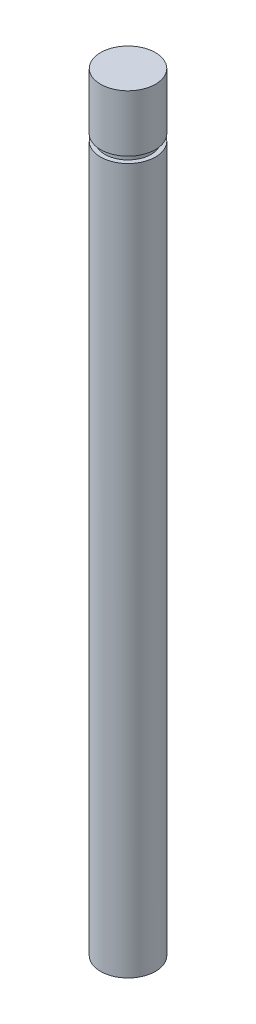
from build123d import *

# Parameters (mm, degrees)
SKETCH1_R           = 3.175
BOSS_EXTRUDE1_DEPTH = 88.9
CUT_EXTRUDE1_DEPTH  = 50.8
CUT_EXTRUDE2_START  = -6.5532
SKETCH3_R           = 3.175
SKETCH3_R_2         = 2.667
CUT_EXTRUDE2_DEPTH  = 0.7366


with BuildPart() as part:
    # Sketch1 → Boss-Extrude1 (new body)
    with BuildSketch(Plane(origin=(0, 0, 0), x_dir=(1, 0, 0), z_dir=(0, 1, 0))):
        Circle(SKETCH1_R)
    extrude(amount=BOSS_EXTRUDE1_DEPTH)

    # Sketch2 → Cut-Extrude1 (cut)
    with BuildSketch(Plane.XZ):
        Polygon((-2.5, 0), (-2.5, -1.957198253), (-3.175, -1.957198253), (-3.175, 1.957198253), (-2.5, 1.957198253), align=None)
    extrude(amount=-CUT_EXTRUDE1_DEPTH, mode=Mode.SUBTRACT)

    # Sketch3 → Cut-Extrude2 (cut)
    with BuildSketch(Plane(origin=(0, 88.9, 0), x_dir=(1, 0, 0), z_dir=(0, 1, 0)).offset(CUT_EXTRUDE2_START)):
        Circle(SKETCH3_R)
        Circle(SKETCH3_R_2, mode=Mode.SUBTRACT)
    extrude(amount=-CUT_EXTRUDE2_DEPTH, mode=Mode.SUBTRACT)


solid = part.part
